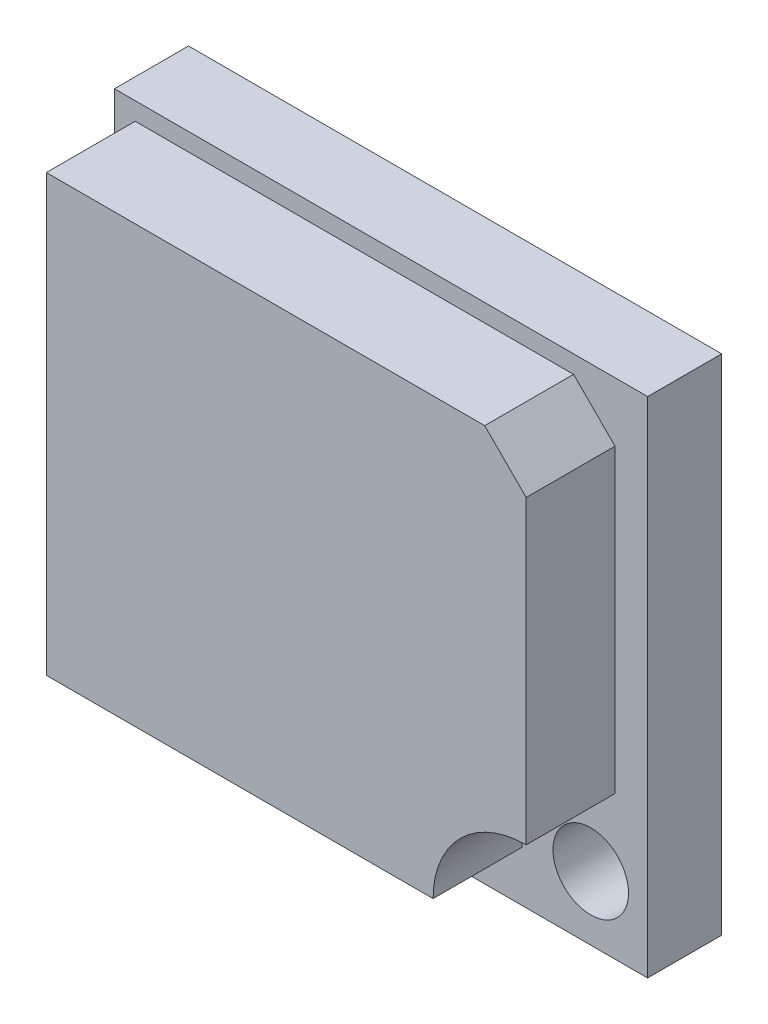
from build123d import *

# Parameters (mm, degrees)
SKIZZE1_W                       = 18
SKIZZE1_H                       = 17
AUFSATZ_LINEAR_AUSTRAGEN1_DEPTH = 2.5
AUFSATZ_LINEAR_AUSTRAGEN2_DEPTH = 3
SKIZZE3_R                       = 1.275
SCHNITT_LINEAR_AUSTRAGEN1_DEPTH = 3.5


with BuildPart() as part:
    # Skizze1 → Aufsatz-Linear austragen1 (new body)
    with BuildSketch(Plane.XY):
        with Locations((9, 8.5)):
            Rectangle(SKIZZE1_W, SKIZZE1_H)
    extrude(amount=AUFSATZ_LINEAR_AUSTRAGEN1_DEPTH)

    # Skizze2 → Aufsatz-Linear austragen2 (add)
    with BuildSketch(Plane.XY.offset(2.5)):
        with BuildLine():
            Line((0.7, 16.4), (0.7, 1.7))
            Line((0.7, 1.7), (13.757142947, 1.7))
            ThreePointArc((13.757142947, 1.7), (14.677664466, 3.922335534), (16.9, 4.842857053))
            Line((16.9, 4.842857053), (16.9, 15))
            Line((16.9, 15), (15.5, 16.4))
            Line((15.5, 16.4), (0.7, 16.4))
        make_face()
    extrude(amount=AUFSATZ_LINEAR_AUSTRAGEN2_DEPTH)

    # Skizze3 → Schnitt-Linear austragen1 (cut, through all)
    with BuildSketch(Plane.XY.offset(2.5)):
        with Locations((16.079023471, 2.15759118)):
            Circle(SKIZZE3_R)
    extrude(amount=-SCHNITT_LINEAR_AUSTRAGEN1_DEPTH, mode=Mode.SUBTRACT)


solid = part.part
